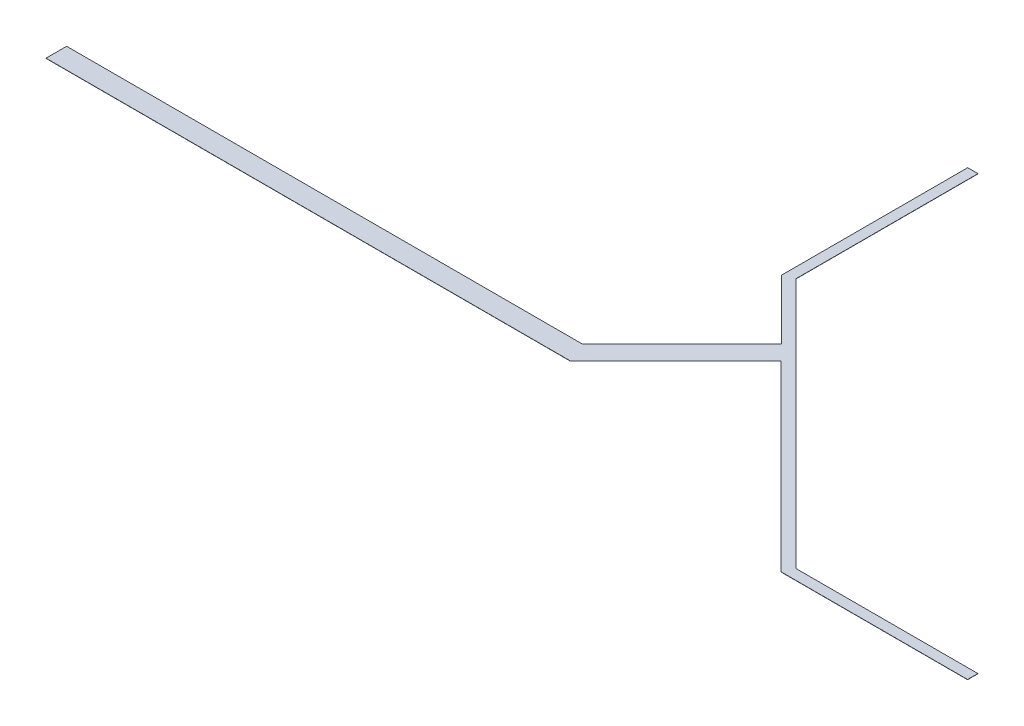
from build123d import *

# Parameters (mm, degrees)
BOSS_EXTRUDE1_DEPTH = 0.02


with BuildPart() as part:
    # Sketch1 → Boss-Extrude1 (new body)
    with BuildSketch(Plane(origin=(0, 0, 0), x_dir=(1, 0, 0), z_dir=(0, 1, 0))):
        Polygon((0, 0), (0, 2), (50, 2), (59.652007563, 11.652007563), (53.889087297, 17.41492783), (53.889087297, 35.49492783), (54.889087297, 35.49492783), (54.889087297, 17.83492783), (79.209002128, -6.495331881), (96.869002128, -6.495331881), (96.869002128, -7.495331881), (78.789002128, -7.495331881), (61.061835124, 10.231835124), (50.83, 0), align=None)
    extrude(amount=BOSS_EXTRUDE1_DEPTH)


solid = part.part
